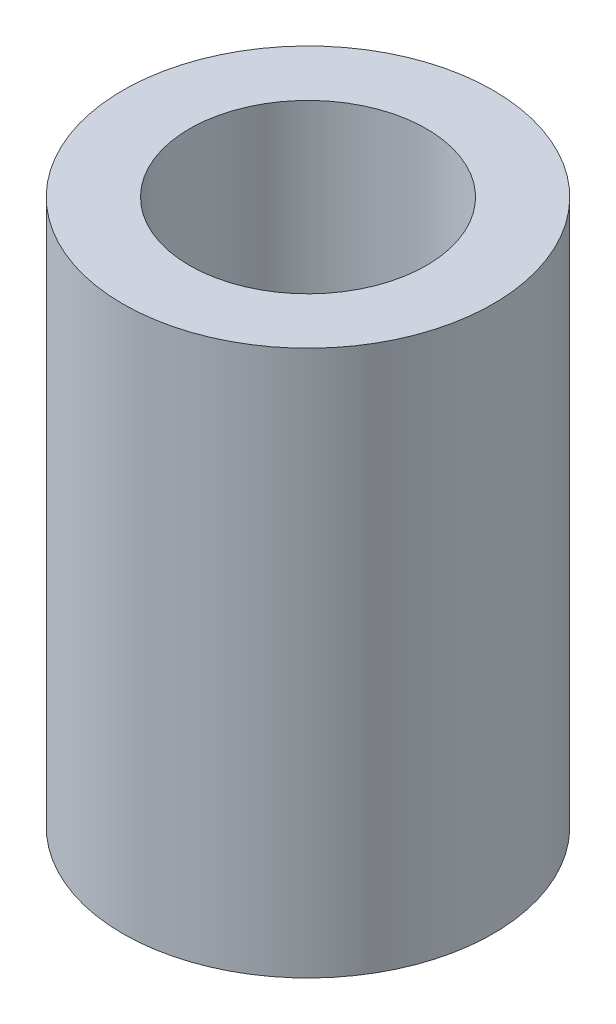
from build123d import *

# Parameters (mm, degrees)
SKETCH1_R           = 2.5
SKETCH1_R_2         = 1.6
BOSS_EXTRUDE1_DEPTH = 7.366


with BuildPart() as part:
    # Sketch1 → Boss-Extrude1 (new body)
    with BuildSketch(Plane(origin=(0, 0, 0), x_dir=(1, 0, 0), z_dir=(0, 1, 0))):
        Circle(SKETCH1_R)
        Circle(SKETCH1_R_2, mode=Mode.SUBTRACT)
    extrude(amount=BOSS_EXTRUDE1_DEPTH)


solid = part.part
